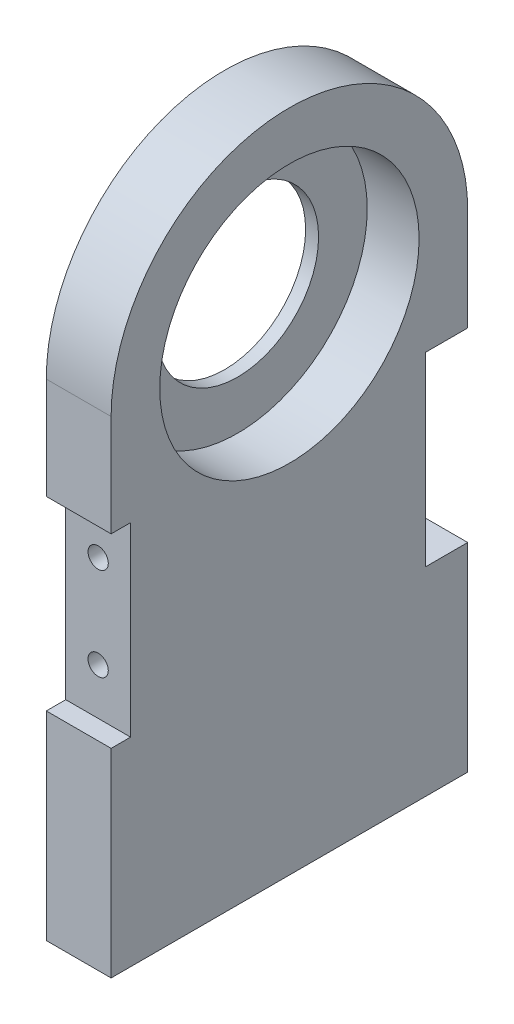
from build123d import *

# Parameters (mm, degrees)
BOSS_EXTRUDE1_DEPTH              = 20
SKETCH3_R                        = 40
CUT_EXTRUDE1_DEPTH               = 16
SKETCH4_R                        = 25
CUT_EXTRUDE2_DEPTH               = 11.1125
TAP_DRILL_FOR_M6X1_0_TAP2_D      = 5
TAP_DRILL_FOR_M6X1_0_TAP2_DEPTH  = 40
TAP_DRILL_FOR_M6X1_0_TAP2_TIP    = 1.502151548
SKETCH12_W                       = 6
SKETCH12_H                       = 57.3
SKETCH12_W_2                     = 13
CUT_EXTRUDE3_DEPTH               = 20
TAP_DRILL_FOR_M6_HELICOIL1_D     = 6.25
TAP_DRILL_FOR_M6_HELICOIL1_DEPTH = 20
TAP_DRILL_FOR_M6_HELICOIL1_TIP   = 1.877689434
TAP_DRILL_FOR_M6_HELICOIL2_D     = 6.25
TAP_DRILL_FOR_M6_HELICOIL2_DEPTH = 20
TAP_DRILL_FOR_M6_HELICOIL2_TIP   = 1.877689434


with BuildPart() as part:
    # Sketch2 → Boss-Extrude1 (new body)
    with BuildSketch(Plane(origin=(0, 0, 0), x_dir=(0, 0, -1), z_dir=(1, 0, 0))):
        with BuildLine():
            Line((55, -75), (55, 75))
            ThreePointArc((55, 75), (0, 20), (-55, 75))
            Line((-55, 75), (-55, -75))
            Line((-55, -75), (55, -75))
        make_face()
        with BuildLine():
            ThreePointArc((-55, 75), (0, 20), (55, 75))
            Line((55, 75), (-55, 75))
        make_face()
        with BuildLine():
            Line((-55, 75), (55, 75))
            ThreePointArc((55, 75), (0, 130), (-55, 75))
        make_face()
    extrude(amount=BOSS_EXTRUDE1_DEPTH)

    # Sketch3 → Cut-Extrude1 (cut)
    with BuildSketch(Plane(origin=(20, 0, 0), x_dir=(0, 0, -1), z_dir=(1, 0, 0))):
        with Locations((0, 75)):
            Circle(SKETCH3_R)
    extrude(amount=-CUT_EXTRUDE1_DEPTH, mode=Mode.SUBTRACT)

    # Sketch4 → Cut-Extrude2 (cut)
    with BuildSketch(Plane(origin=(4, 0, 0), x_dir=(0, 0, -1), z_dir=(1, 0, 0))):
        with Locations((0, 75)):
            Circle(SKETCH4_R)
    extrude(amount=-CUT_EXTRUDE2_DEPTH, mode=Mode.SUBTRACT)

    # Tap Drill for M6x1.0 Tap2
    with Locations(Plane(origin=(0, -75, 0), x_dir=(-1, 0, 0), z_dir=(0, -1, 0))):
        with Locations((-10, -36.666666667), (-10, -18.333333333), (-10, 0), (-10, 18.333333333), (-10, 36.666666667)):
            Hole(TAP_DRILL_FOR_M6X1_0_TAP2_D / 2, depth=TAP_DRILL_FOR_M6X1_0_TAP2_DEPTH)
            with Locations((0, 0, -(TAP_DRILL_FOR_M6X1_0_TAP2_DEPTH + TAP_DRILL_FOR_M6X1_0_TAP2_TIP / 2))):  # 118° drill point
                Cone(0, TAP_DRILL_FOR_M6X1_0_TAP2_D / 2, TAP_DRILL_FOR_M6X1_0_TAP2_TIP, mode=Mode.SUBTRACT)

    # Sketch12 → Cut-Extrude3 (cut)
    with BuildSketch(Plane(origin=(20, 0, 0), x_dir=(0, 0, -1), z_dir=(1, 0, 0))):
        with Locations((-52, 15)):
            Rectangle(SKETCH12_W, SKETCH12_H)
        with Locations((48.5, 15)):
            Rectangle(SKETCH12_W_2, SKETCH12_H)
    extrude(amount=-CUT_EXTRUDE3_DEPTH, mode=Mode.SUBTRACT)

    # Tap Drill for M6 Helicoil1
    with Locations(Plane(origin=(10, 29.325, 49), x_dir=(1, 0, 0), z_dir=(0, 0, 1))):
        with Locations((0, 0), (0, -28.65)):
            Hole(TAP_DRILL_FOR_M6_HELICOIL1_D / 2, depth=TAP_DRILL_FOR_M6_HELICOIL1_DEPTH)
            with Locations((0, 0, -(TAP_DRILL_FOR_M6_HELICOIL1_DEPTH + TAP_DRILL_FOR_M6_HELICOIL1_TIP / 2))):  # 118° drill point
                Cone(0, TAP_DRILL_FOR_M6_HELICOIL1_D / 2, TAP_DRILL_FOR_M6_HELICOIL1_TIP, mode=Mode.SUBTRACT)

    # Tap Drill for M6 Helicoil2
    with Locations(Plane(origin=(0, 0, -42), x_dir=(-1, 0, 0), z_dir=(0, 0, -1))):
        with Locations((-10, 29.325), (-10, 0.675)):
            Hole(TAP_DRILL_FOR_M6_HELICOIL2_D / 2, depth=TAP_DRILL_FOR_M6_HELICOIL2_DEPTH)
            with Locations((0, 0, -(TAP_DRILL_FOR_M6_HELICOIL2_DEPTH + TAP_DRILL_FOR_M6_HELICOIL2_TIP / 2))):  # 118° drill point
                Cone(0, TAP_DRILL_FOR_M6_HELICOIL2_D / 2, TAP_DRILL_FOR_M6_HELICOIL2_TIP, mode=Mode.SUBTRACT)


solid = part.part
